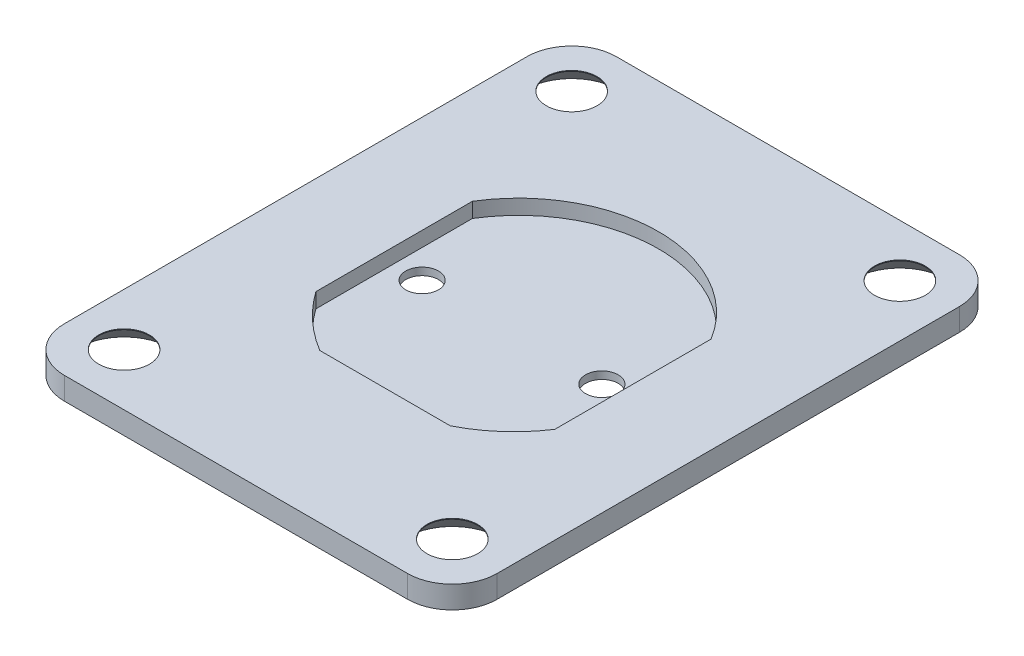
from build123d import *

# Parameters (mm, degrees)
SKETCH5_W                                    = 29
SKETCH5_H                                    = 37
BOSS_EXTRUDE3_DEPTH                          = 0.5
SKETCH6_R                                    = 1.095
CUT_EXTRUDE1_DEPTH                           = 1
CUT_EXTRUDE1_DEPTH_BACK                      = 1.5
SKETCH7_W                                    = 29
SKETCH7_H                                    = 37
BOSS_EXTRUDE4_DEPTH                          = 1
FILLET1_R                                    = 3
CSK_FOR_M3_COUNTERSUNK_FLAT_HEAD_SCR_2_COUNT = 2
CSK_FOR_M3_COUNTERSUNK_FLAT_HEAD_SCR_2_PITCH = 22
CSK_FOR_M3_COUNTERSUNK_FLAT_HEAD_SCR_3_COUNT = 2
CSK_FOR_M3_COUNTERSUNK_FLAT_HEAD_SCR_3_PITCH = 37.202150475
CSK_FOR_M3_COUNTERSUNK_FLAT_HEAD_SCR_4_COUNT = 2
CSK_FOR_M3_COUNTERSUNK_FLAT_HEAD_SCR_4_PITCH = 30


with BuildPart() as part:
    # Sketch5 → Boss-Extrude3 (new body)
    with BuildSketch(Plane(origin=(0, 0, 0), x_dir=(1, 0, 0), z_dir=(0, 1, 0))):
        Rectangle(SKETCH5_W, SKETCH5_H)
    extrude(amount=BOSS_EXTRUDE3_DEPTH)

    # Sketch6 → Cut-Extrude1 (cut, two sides)
    with BuildSketch(Plane(origin=(0, 0.5, 0), x_dir=(1, 0, 0), z_dir=(0, 1, 0))) as cut_extrude1_sk:
        with Locations((-6.025, 0)):
            Circle(SKETCH6_R)
        with Locations((6.025, 0)):
            Circle(SKETCH6_R)
    extrude(amount=CUT_EXTRUDE1_DEPTH, mode=Mode.SUBTRACT)
    extrude(cut_extrude1_sk.sketch, amount=-CUT_EXTRUDE1_DEPTH_BACK, mode=Mode.SUBTRACT)

    # Sketch7 → Boss-Extrude4 (add)
    with BuildSketch(Plane(origin=(0, 0.5, 0), x_dir=(1, 0, 0), z_dir=(0, 1, 0))):
        Rectangle(SKETCH7_W, SKETCH7_H)
        with BuildLine():
            ThreePointArc((4.362935735, -8.496468579), (6.43071599, -7.092318659), (8.065752838, -5.201814312))
            Line((8.065752838, -5.201814312), (8.065752838, 5.280856896))
            ThreePointArc((8.065752838, 5.280856896), (0.065752838, 9.758587375), (-7.934247162, 5.280856896))
            Line((-7.934247162, 5.280856896), (-7.934247162, -5.211512098))
            ThreePointArc((-7.934247162, -5.211512098), (-6.328814647, -7.036583971), (-4.385354374, -8.496468579))
            Line((-4.385354374, -8.496468579), (4.362935735, -8.496468579))
        make_face(mode=Mode.SUBTRACT)
    extrude(amount=BOSS_EXTRUDE4_DEPTH)

    # Fillet1
    fillet1_edges = [part.edges().sort_by_distance(p)[0] for p in [
        (-14.5, 0.75, -18.5),
        (14.5, 0.75, -18.5),
        (14.5, 0.75, 18.5),
        (-14.5, 0.75, 18.5),
    ]]
    fillet(fillet1_edges, radius=FILLET1_R)

    # Sketch11 → CSK for M3 Countersunk Flat Head Screw1 (revolve, cut)
    with BuildSketch(Plane(origin=(-11, 0, -15), x_dir=(0, 0, -1), z_dir=(1, 0, 0))):
        Polygon((0, 0), (0, 1.5), (1.7, 1.5), (1.7, 1.45), (3.15, 0), align=None)
    csk_for_m3_countersunk_flat_head_screw1 = revolve(axis=Axis((-11, -6.35, -15), (0, 1, 0)), mode=Mode.SUBTRACT)

    # CSK for M3 Countersunk Flat Head Scr 2: CSK for M3 Countersunk Flat Head Screw1 ×2
    with Locations(*[(i * CSK_FOR_M3_COUNTERSUNK_FLAT_HEAD_SCR_2_PITCH, 0, 0) for i in range(1, CSK_FOR_M3_COUNTERSUNK_FLAT_HEAD_SCR_2_COUNT)]):
        add(csk_for_m3_countersunk_flat_head_screw1, mode=Mode.SUBTRACT)

    # CSK for M3 Countersunk Flat Head Scr 3: CSK for M3 Countersunk Flat Head Screw1 ×2
    with Locations(*[Vector(0.591363664, 0, 0.806404996) * (i * CSK_FOR_M3_COUNTERSUNK_FLAT_HEAD_SCR_3_PITCH) for i in range(1, CSK_FOR_M3_COUNTERSUNK_FLAT_HEAD_SCR_3_COUNT)]):
        add(csk_for_m3_countersunk_flat_head_screw1, mode=Mode.SUBTRACT)

    # CSK for M3 Countersunk Flat Head Scr 4: CSK for M3 Countersunk Flat Head Screw1 ×2
    with Locations(*[(0, 0, i * CSK_FOR_M3_COUNTERSUNK_FLAT_HEAD_SCR_4_PITCH) for i in range(1, CSK_FOR_M3_COUNTERSUNK_FLAT_HEAD_SCR_4_COUNT)]):
        add(csk_for_m3_countersunk_flat_head_screw1, mode=Mode.SUBTRACT)


solid = part.part
